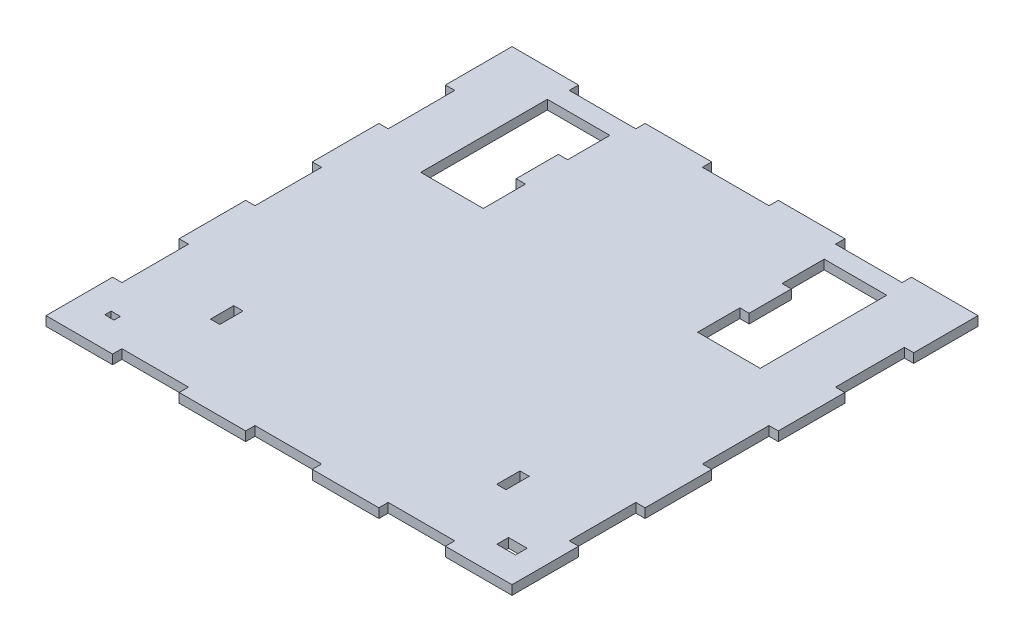
from build123d import *

# Parameters (mm, degrees)
SKETCH1_W           = 254
SKETCH1_H           = 254
BOSS_EXTRUDE1_DEPTH = 5.08
SKETCH2_W           = 36.285714285
SKETCH2_H           = 5.08
SKETCH2_W_2         = 36.285714286
CUT_EXTRUDE1_DEPTH  = 5.08
SKETCH3_W           = 36.285714285
SKETCH3_H           = 5.08
SKETCH3_W_2         = 36.285714286
SKETCH3_W_3         = 37.524307816
CUT_EXTRUDE2_DEPTH  = 5.08
SKETCH4_W           = 36.285714285
SKETCH4_H           = 5.08
SKETCH4_W_2         = 36.285714286
CUT_EXTRUDE3_DEPTH  = 5.08
SKETCH5_W           = 36.285714285
SKETCH5_H           = 5.08
SKETCH5_W_2         = 36.285714286
CUT_EXTRUDE4_DEPTH  = 5.08
SKETCH6_W           = 29
SKETCH6_H           = 69
CUT_EXTRUDE5_DEPTH  = 5.08
CUT_EXTRUDE6_DEPTH  = 5.08
SKETCH8_W           = 5.08
SKETCH8_H           = 12.7
CUT_EXTRUDE7_DEPTH  = 5.08
SKETCH9_W           = 23
SKETCH9_H           = 5.08
CUT_EXTRUDE8_DEPTH  = 5.08
SKETCH10_W          = 23
SKETCH10_H          = 5.08
CUT_EXTRUDE9_DEPTH  = 5.08
SKETCH11_W          = 10.16
SKETCH11_H          = 6.35
CUT_EXTRUDE10_DEPTH = 5.08
SKETCH12_W          = 4.99581634
SKETCH12_H          = 3.489472518
CUT_EXTRUDE11_DEPTH = 5.08


with BuildPart() as part:
    # Sketch1 → Boss-Extrude1 (new body)
    with BuildSketch(Plane(origin=(0, 0, 0), x_dir=(1, 0, 0), z_dir=(0, 1, 0))):
        with Locations((-127, 127)):
            Rectangle(SKETCH1_W, SKETCH1_H)
    extrude(amount=BOSS_EXTRUDE1_DEPTH)

    # Sketch2 → Cut-Extrude1 (cut)
    with BuildSketch(Plane.XY):
        with Locations((-199.571428572, 2.54)):
            Rectangle(SKETCH2_W, SKETCH2_H)
        with Locations((-127, 2.54)):
            Rectangle(SKETCH2_W_2, SKETCH2_H)
        with Locations((-54.428571428, 2.54)):
            Rectangle(SKETCH2_W, SKETCH2_H)
    extrude(amount=-CUT_EXTRUDE1_DEPTH, mode=Mode.SUBTRACT)

    # Sketch3 → Cut-Extrude2 (cut)
    with BuildSketch(Plane(origin=(0, 0, 0), x_dir=(0, 0, -1), z_dir=(1, 0, 0))):
        with Locations((54.428571428, 2.54)):
            Rectangle(SKETCH3_W, SKETCH3_H)
        with Locations((127, 2.54)):
            Rectangle(SKETCH3_W_2, SKETCH3_H)
        with Locations((200.190725337, 2.54)):
            Rectangle(SKETCH3_W_3, SKETCH3_H)
    extrude(amount=-CUT_EXTRUDE2_DEPTH, mode=Mode.SUBTRACT)

    # Sketch4 → Cut-Extrude3 (cut)
    with BuildSketch(Plane(origin=(0, 0, -254), x_dir=(-1, 0, 0), z_dir=(0, 0, -1))):
        with Locations((54.428571428, 2.54)):
            Rectangle(SKETCH4_W, SKETCH4_H)
        with Locations((127, 2.54)):
            Rectangle(SKETCH4_W_2, SKETCH4_H)
        with Locations((199.571428572, 2.54)):
            Rectangle(SKETCH4_W, SKETCH4_H)
    extrude(amount=-CUT_EXTRUDE3_DEPTH, mode=Mode.SUBTRACT)

    # Sketch5 → Cut-Extrude4 (cut)
    with BuildSketch(Plane.ZY.offset(254)):
        with Locations((-199.571428572, 2.54)):
            Rectangle(SKETCH5_W, SKETCH5_H)
        with Locations((-127, 2.54)):
            Rectangle(SKETCH5_W_2, SKETCH5_H)
        with Locations((-54.428571428, 2.54)):
            Rectangle(SKETCH5_W, SKETCH5_H)
    extrude(amount=-CUT_EXTRUDE4_DEPTH, mode=Mode.SUBTRACT)

    # Sketch6 → Cut-Extrude5 (cut)
    with BuildSketch(Plane(origin=(0, 5.08, 0), x_dir=(1, 0, 0), z_dir=(0, 1, 0))):
        with Locations((-49, 204.26)):
            Rectangle(SKETCH6_W, SKETCH6_H)
        with Locations((-205, 204.26)):
            Rectangle(SKETCH6_W, SKETCH6_H)
    extrude(amount=-CUT_EXTRUDE5_DEPTH, mode=Mode.SUBTRACT)

    # Sketch7 → Cut-Extrude6 (cut)
    with BuildSketch(Plane(origin=(0, 5.08, 0), x_dir=(1, 0, 0), z_dir=(0, 1, 0))):
        Polygon((-51.54, 43.18), (-49, 43.18), (-46.46, 43.18), (-46.46, 55.88), (-51.54, 55.88), align=None)
    extrude(amount=-CUT_EXTRUDE6_DEPTH, mode=Mode.SUBTRACT)

    # Sketch8 → Cut-Extrude7 (cut)
    with BuildSketch(Plane(origin=(0, 5.08, 0), x_dir=(1, 0, 0), z_dir=(0, 1, 0))):
        with Locations((-205, 49.53)):
            Rectangle(SKETCH8_W, SKETCH8_H)
    extrude(amount=-CUT_EXTRUDE7_DEPTH, mode=Mode.SUBTRACT)

    # Sketch9 → Cut-Extrude8 (cut)
    with BuildSketch(Plane(origin=(-63.5, 0, 0), x_dir=(0, 0, -1), z_dir=(1, 0, 0))):
        with Locations((181.26, 2.54)):
            Rectangle(SKETCH9_W, SKETCH9_H)
        with Locations((227.26, 2.54)):
            Rectangle(SKETCH9_W, SKETCH9_H)
    extrude(amount=-CUT_EXTRUDE8_DEPTH, mode=Mode.SUBTRACT)

    # Sketch10 → Cut-Extrude9 (cut)
    with BuildSketch(Plane.ZY.offset(190.5)):
        with Locations((-181.26, 2.54)):
            Rectangle(SKETCH10_W, SKETCH10_H)
        with Locations((-227.26, 2.54)):
            Rectangle(SKETCH10_W, SKETCH10_H)
    extrude(amount=-CUT_EXTRUDE9_DEPTH, mode=Mode.SUBTRACT)

    # Sketch11 → Cut-Extrude10 (cut)
    with BuildSketch(Plane(origin=(0, 5.08, 0), x_dir=(1, 0, 0), z_dir=(0, 1, 0))):
        with Locations((-18.142857143, 18.142857143)):
            Rectangle(SKETCH11_W, SKETCH11_H)
    extrude(amount=-CUT_EXTRUDE10_DEPTH, mode=Mode.SUBTRACT)

    # Sketch12 → Cut-Extrude11 (cut)
    with BuildSketch(Plane(origin=(0, 5.08, 0), x_dir=(1, 0, 0), z_dir=(0, 1, 0))):
        with Locations((-235.857142857, 18.142857143)):
            Rectangle(SKETCH12_W, SKETCH12_H)
    extrude(amount=-CUT_EXTRUDE11_DEPTH, mode=Mode.SUBTRACT)


solid = part.part
